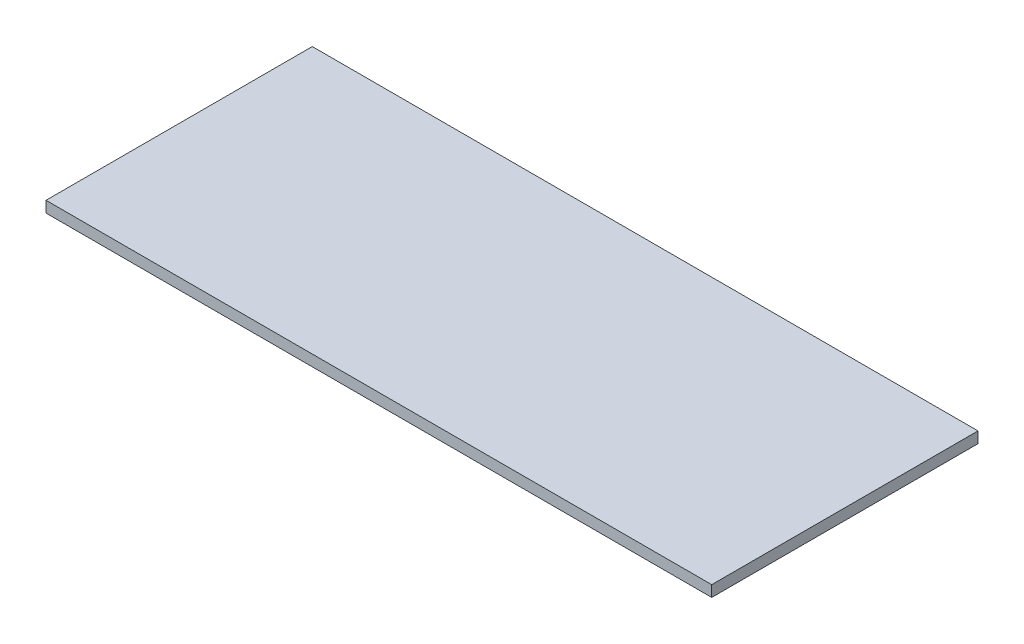
from build123d import *

# Parameters (mm, degrees)
SKETCH1_W           = 38100
SKETCH1_H           = 15240
BOSS_EXTRUDE1_DEPTH = 635


with BuildPart() as part:
    # Sketch1 → Boss-Extrude1 (new body)
    with BuildSketch(Plane(origin=(0, 0, 0), x_dir=(1, 0, 0), z_dir=(0, 1, 0))):
        Rectangle(SKETCH1_W, SKETCH1_H)
    extrude(amount=BOSS_EXTRUDE1_DEPTH)


solid = part.part
